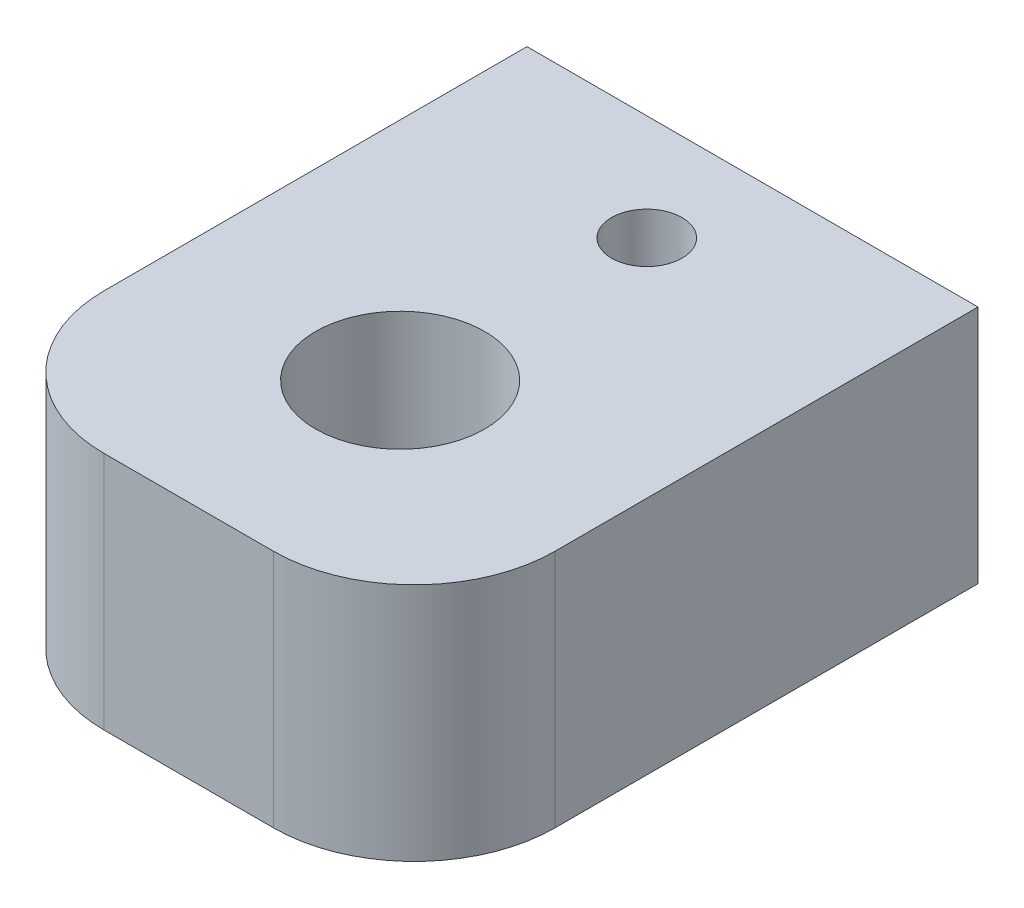
from build123d import *

# Parameters (mm, degrees)
SKETCH1_R           = 2.5
SKETCH1_R_2         = 6
BOSS_EXTRUDE1_DEPTH = 17
SKETCH2_R           = 5
CUT_EXTRUDE1_DEPTH  = 15


with BuildPart() as part:
    # Sketch1 → Boss-Extrude1 (new body)
    with BuildSketch(Plane(origin=(0, 0, 0), x_dir=(1, 0, 0), z_dir=(0, 1, 0))):
        with BuildLine():
            Line((-16, 20), (16, 20))
            Line((16, 20), (16, -10))
            ThreePointArc((16, -10), (13.071067812, -17.071067812), (6, -20))
            Line((6, -20), (-6, -20))
            ThreePointArc((-6, -20), (-13.071067812, -17.071067812), (-16, -10))
            Line((-16, -10), (-16, 20))
        make_face()
        with Locations((0, 12.5)):
            Circle(SKETCH1_R, mode=Mode.SUBTRACT)
        with Locations((0, -5)):
            Circle(SKETCH1_R_2, mode=Mode.SUBTRACT)
    extrude(amount=BOSS_EXTRUDE1_DEPTH)

    # Sketch2 → Cut-Extrude1 (cut)
    with BuildSketch(Plane(origin=(0, 0, -20), x_dir=(-1, 0, 0), z_dir=(0, 0, -1))):
        with Locations((0, 8.5)):
            Circle(SKETCH2_R)
    extrude(amount=-CUT_EXTRUDE1_DEPTH, mode=Mode.SUBTRACT)


solid = part.part
